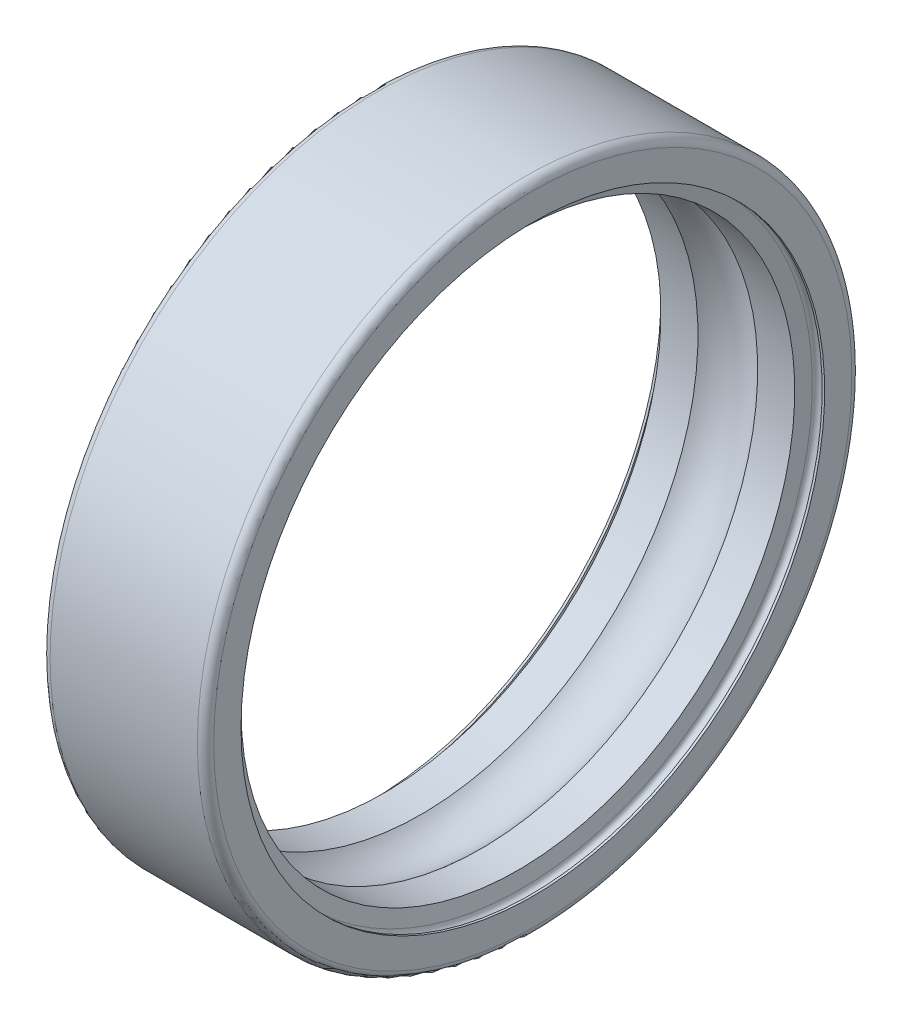
from build123d import *


with BuildPart() as part:
    # Sketch1 → Revolve1 (revolve)
    with BuildSketch(Plane.XY):
        with BuildLine():
            Line((0, 10.7), (0.09, 10.7))
            ThreePointArc((0.09, 10.7), (0.27, 10.88), (0.45, 10.7))
            Line((0.45, 10.7), (0.546979839, 10.15))
            Line((0.546979839, 10.15), (1.905625178, 10.15))
            ThreePointArc((1.905625178, 10.15), (3, 10.5875), (4.094374822, 10.15))
            Line((4.094374822, 10.15), (5.453020161, 10.15))
            Line((5.453020161, 10.15), (5.55, 10.7))
            ThreePointArc((5.55, 10.7), (5.73, 10.88), (5.91, 10.7))
            Line((5.91, 10.7), (6, 10.7))
            Line((6, 10.7), (6, 11.7))
            ThreePointArc((6, 11.7), (5.912132034, 11.912132034), (5.7, 12))
            Line((5.7, 12), (0.3, 12))
            ThreePointArc((0.3, 12), (0.087867966, 11.912132034), (0, 11.7))
            Line((0, 11.7), (0, 10.7))
        make_face()
    revolve(axis=Axis((50, 0, 0), (-1, 0, 0)))


solid = part.part
